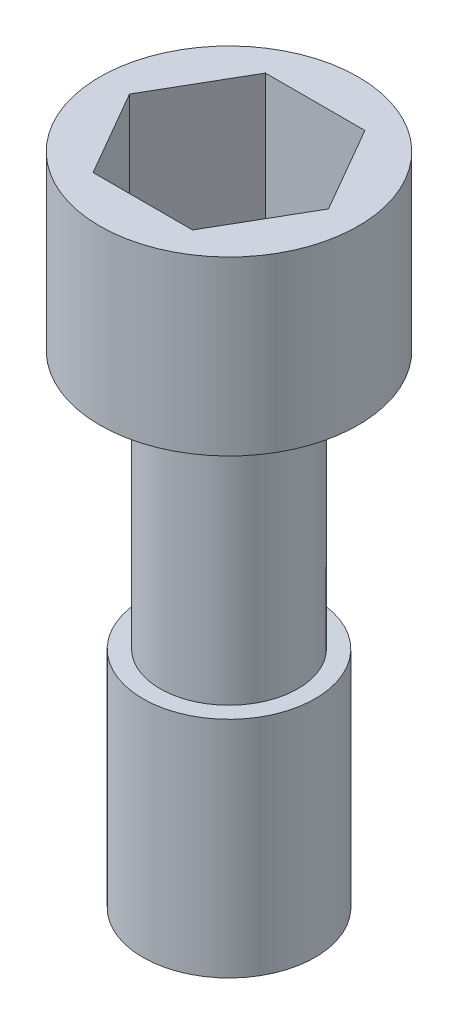
from build123d import *

# Parameters (mm, degrees)
SKETCH1_R           = 7.5
BOSS_EXTRUDE1_DEPTH = 8
BOSS_EXTRUDE2_START = 2
SKETCH2_R           = 7.5
BOSS_EXTRUDE2_DEPTH = 2
SKETCH2_3_R         = 4
BOSS_EXTRUDE3_DEPTH = 17
SKETCH3_R           = 5
BOSS_EXTRUDE4_DEPTH = 13


with BuildPart() as part:
    # Sketch1 → Boss-Extrude1 (new body)
    with BuildSketch(Plane(origin=(0, 0, 0), x_dir=(1, 0, 0), z_dir=(0, 1, 0))):
        Circle(SKETCH1_R)
        Polygon((5.773502692, 0), (2.886751346, 5), (-2.886751346, 5), (-5.773502692, 0), (-2.886751346, -5), (2.886751346, -5), align=None, mode=Mode.SUBTRACT)
    extrude(amount=BOSS_EXTRUDE1_DEPTH)

    # Sketch2 → Boss-Extrude2 (add)
    with BuildSketch(Plane.XZ.offset(BOSS_EXTRUDE2_START)):
        Circle(SKETCH2_R)
    extrude(amount=-BOSS_EXTRUDE2_DEPTH)

    # Sketch2_3 → Boss-Extrude3 (add)
    with BuildSketch(Plane.XZ):
        Circle(SKETCH2_3_R)
    extrude(amount=BOSS_EXTRUDE3_DEPTH)

    # Sketch3 → Boss-Extrude4 (add)
    with BuildSketch(Plane.XZ.offset(17)):
        Circle(SKETCH3_R)
    extrude(amount=BOSS_EXTRUDE4_DEPTH)


solid = part.part
